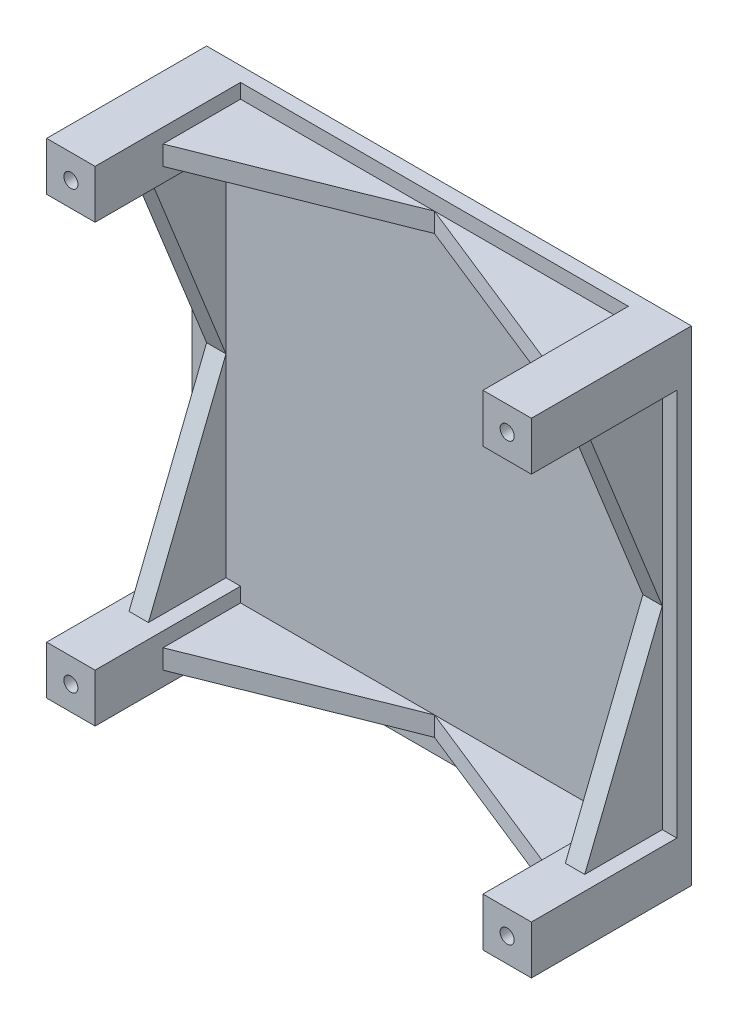
from build123d import *

# Parameters (mm, degrees)
EXTRUDE_3_DEPTH     = 3
SKETCH_1_4_W        = 10
SKETCH_1_4_H        = 10
EXTRUDE_4_DEPTH     = 33
CUT_EXTRUDE_1_DEPTH = 16
CUT_EXTRUDE_2_DEPTH = 16
CUT_EXTRUDE_3_DEPTH = 16
CUT_EXTRUDE_4_DEPTH = 16
SKETCH_7_W          = 4
SKETCH_7_H          = 80
SKETCH_7_W_2        = 80
SKETCH_7_H_2        = 4
EXTRUDE_5_DEPTH     = 16
CUT_EXTRUDE_5_DEPTH = 16
CUT_EXTRUDE_6_DEPTH = 16
CUT_EXTRUDE_7_DEPTH = 16
CUT_EXTRUDE_8_DEPTH = 16


with BuildPart() as part:
    # 草图1 → 凸台-拉伸3 (new body)
    with BuildSketch(Plane.XY):
        Polygon((10, 10), (10, 0), (90, 0), (90, 10), (100, 10), (100, 90), (90, 90), (90, 100), (10, 100), (10, 90), (0, 90), (0, 10), align=None)
    extrude(amount=EXTRUDE_3_DEPTH)

    # 草图1<4> → 凸台-拉伸4 (add)
    with BuildSketch(Plane.XY):
        with Locations((5, 5)):
            Rectangle(SKETCH_1_4_W, SKETCH_1_4_H)
        with Locations((95, 5)):
            Rectangle(SKETCH_1_4_W, SKETCH_1_4_H)
        with Locations((5, 95)):
            Rectangle(SKETCH_1_4_W, SKETCH_1_4_H)
        with Locations((95, 95)):
            Rectangle(SKETCH_1_4_W, SKETCH_1_4_H)
    extrude(amount=EXTRUDE_4_DEPTH)

    # 草图3 → 切除-拉伸1 (cut)
    with BuildSketch(Plane.XY.offset(33)):
        with BuildLine():
            ThreePointArc((5, 96.45), (3.974695167, 93.974695167), (6.45, 95))
            ThreePointArc((6.45, 95), (6.025304833, 96.025304833), (5, 96.45))
        make_face()
    extrude(amount=-CUT_EXTRUDE_1_DEPTH, mode=Mode.SUBTRACT)

    # 草图4 → 切除-拉伸2 (cut)
    with BuildSketch(Plane.XY.offset(33)):
        with BuildLine():
            ThreePointArc((95, 96.45), (93.974695167, 93.974695167), (96.45, 95))
            ThreePointArc((96.45, 95), (96.025304833, 96.025304833), (95, 96.45))
        make_face()
    extrude(amount=-CUT_EXTRUDE_2_DEPTH, mode=Mode.SUBTRACT)

    # 草图5 → 切除-拉伸3 (cut)
    with BuildSketch(Plane.XY.offset(33)):
        with BuildLine():
            ThreePointArc((5, 3.55), (6.025304833, 3.974695167), (6.45, 5))
            ThreePointArc((6.45, 5), (3.974695167, 6.025304833), (5, 3.55))
        make_face()
    extrude(amount=-CUT_EXTRUDE_3_DEPTH, mode=Mode.SUBTRACT)

    # 草图5<3> → 切除-拉伸4 (cut)
    with BuildSketch(Plane.XY.offset(33)):
        with BuildLine():
            ThreePointArc((95, 6.45), (93.974695167, 3.974695167), (96.45, 5))
            ThreePointArc((96.45, 5), (96.025304833, 6.025304833), (95, 6.45))
        make_face()
    extrude(amount=-CUT_EXTRUDE_4_DEPTH, mode=Mode.SUBTRACT)

    # 草图7 → 凸台-拉伸5 (add)
    with BuildSketch(Plane.XY.offset(3)):
        with Locations((5, 50)):
            Rectangle(SKETCH_7_W, SKETCH_7_H)
        with Locations((50, 95)):
            Rectangle(SKETCH_7_W_2, SKETCH_7_H_2)
        with Locations((50, 5)):
            Rectangle(SKETCH_7_W_2, SKETCH_7_H_2)
        with Locations((95, 50)):
            Rectangle(SKETCH_7_W, SKETCH_7_H)
    extrude(amount=EXTRUDE_5_DEPTH)

    # 草图8 → 切除-拉伸5 (cut)
    with BuildSketch(Plane(origin=(0, 7, 0), x_dir=(1, 0, 0), z_dir=(0, 1, 0))):
        Polygon((89.910217028, -19), (50, -3), (10, -19), align=None)
    extrude(amount=-CUT_EXTRUDE_5_DEPTH, mode=Mode.SUBTRACT)

    # 草图9 → 切除-拉伸6 (cut)
    with BuildSketch(Plane(origin=(7, 0, 0), x_dir=(0, 0, -1), z_dir=(1, 0, 0))):
        Polygon((-19, 10), (-3, 50), (-19, 90), align=None)
    extrude(amount=-CUT_EXTRUDE_6_DEPTH, mode=Mode.SUBTRACT)

    # 草图10 → 切除-拉伸7 (cut)
    with BuildSketch(Plane.XZ.offset(-93)):
        Polygon((10, 19), (50, 3), (90, 19), align=None)
    extrude(amount=-CUT_EXTRUDE_7_DEPTH, mode=Mode.SUBTRACT)

    # 草图11 → 切除-拉伸8 (cut)
    with BuildSketch(Plane.ZY.offset(-93)):
        Polygon((19, 90), (3, 50), (19, 10), align=None)
    extrude(amount=-CUT_EXTRUDE_8_DEPTH, mode=Mode.SUBTRACT)


solid = part.part
